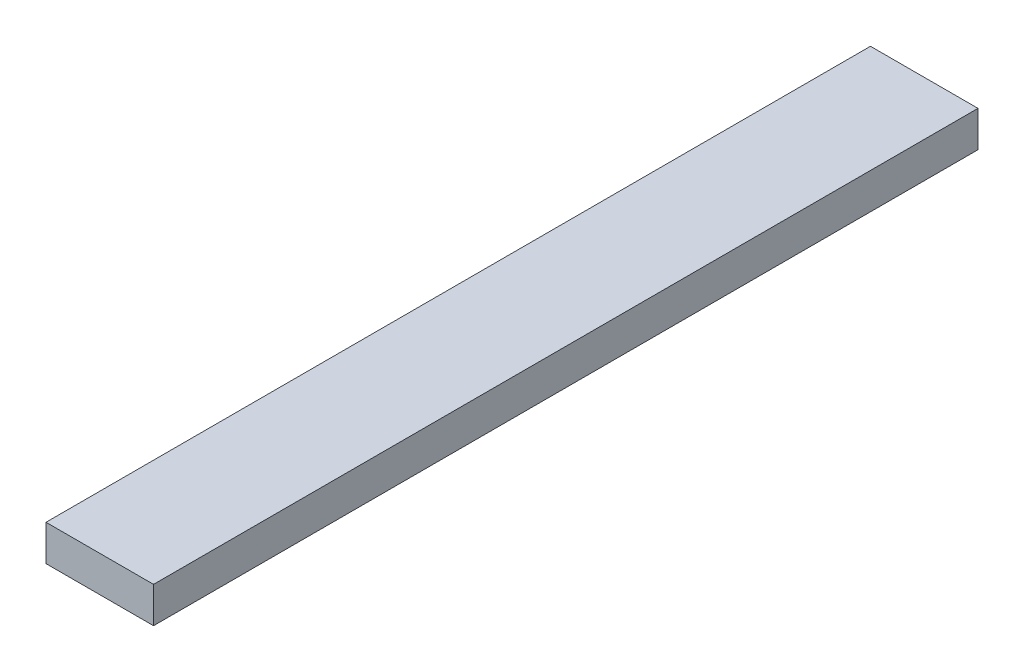
from build123d import *

# Parameters (mm, degrees)
SKETCH1_W           = 60
SKETCH1_H           = 20
BOSS_EXTRUDE1_DEPTH = 230


with BuildPart() as part:
    # Sketch1 → Boss-Extrude1 (new body, symmetric)
    with BuildSketch(Plane.XY):
        Rectangle(SKETCH1_W, SKETCH1_H)
    extrude(amount=BOSS_EXTRUDE1_DEPTH, both=True)


solid = part.part
